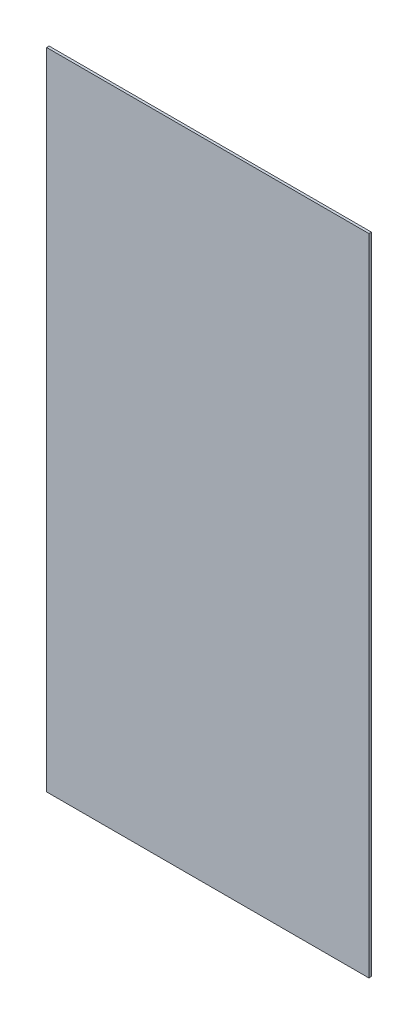
from build123d import *

# Parameters (mm, degrees)
SKETCH_1_W  = 50
SKETCH_1_H  = 100
BOARD_DEPTH = 0.39116


with BuildPart() as part:
    # Эскиз1 → Board (new body)
    with BuildSketch(Plane.XY):
        with Locations((50.4, 75.4)):
            Rectangle(SKETCH_1_W, SKETCH_1_H)
    extrude(amount=BOARD_DEPTH)


solid = part.part
